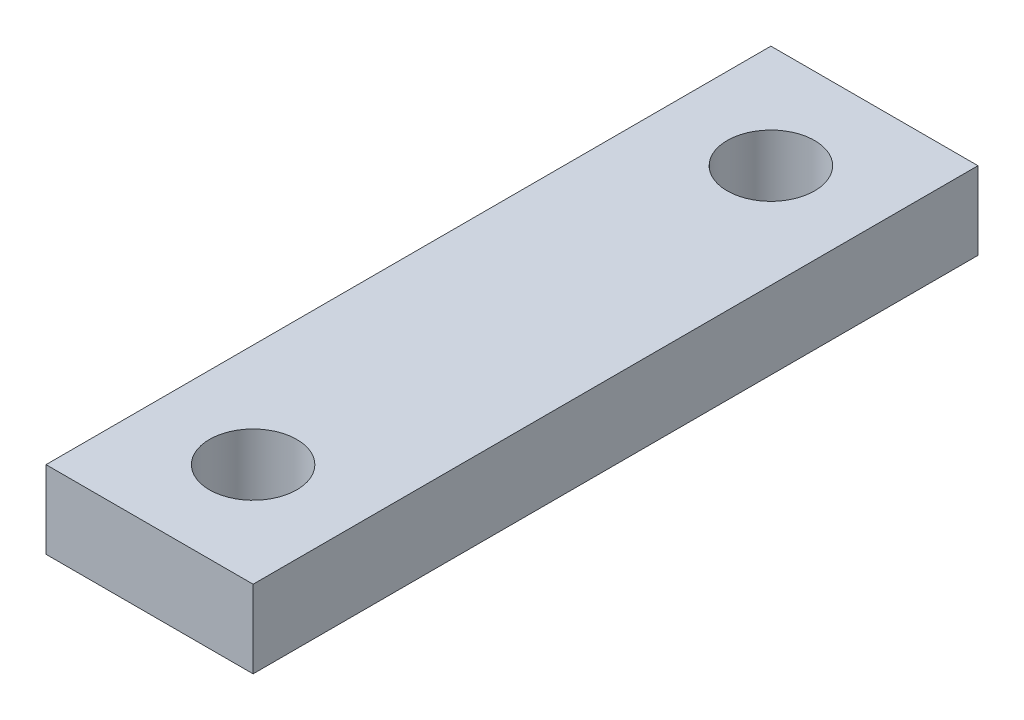
from build123d import *

# Parameters (mm, degrees)
SKETCH1_W                   = 25.4
SKETCH1_H                   = 9.525
EXTRUDE1_DEPTH              = 44.45
TAP_DRILL_FOR_1_2_13_TAP1_D = 10.71626


with BuildPart() as part:
    # Sketch1 → Extrude1 (new body, symmetric)
    with BuildSketch(Plane.XY):
        Rectangle(SKETCH1_W, SKETCH1_H)
    extrude(amount=EXTRUDE1_DEPTH, both=True)

    # Tap Drill for 1/2-13 Tap1 (through all)
    with Locations(Plane(origin=(0, 4.7625, -31.75), x_dir=(0, 0, 1), z_dir=(0, 1, 0))):
        with Locations((0, 0)):
            tap_drill_for_1_2_13_tap1 = Hole(TAP_DRILL_FOR_1_2_13_TAP1_D / 2)

    # Mirror1: Tap Drill for 1/2-13 Tap1 across plane
    add(tap_drill_for_1_2_13_tap1.mirror(Plane.XY), mode=Mode.SUBTRACT)


solid = part.part
